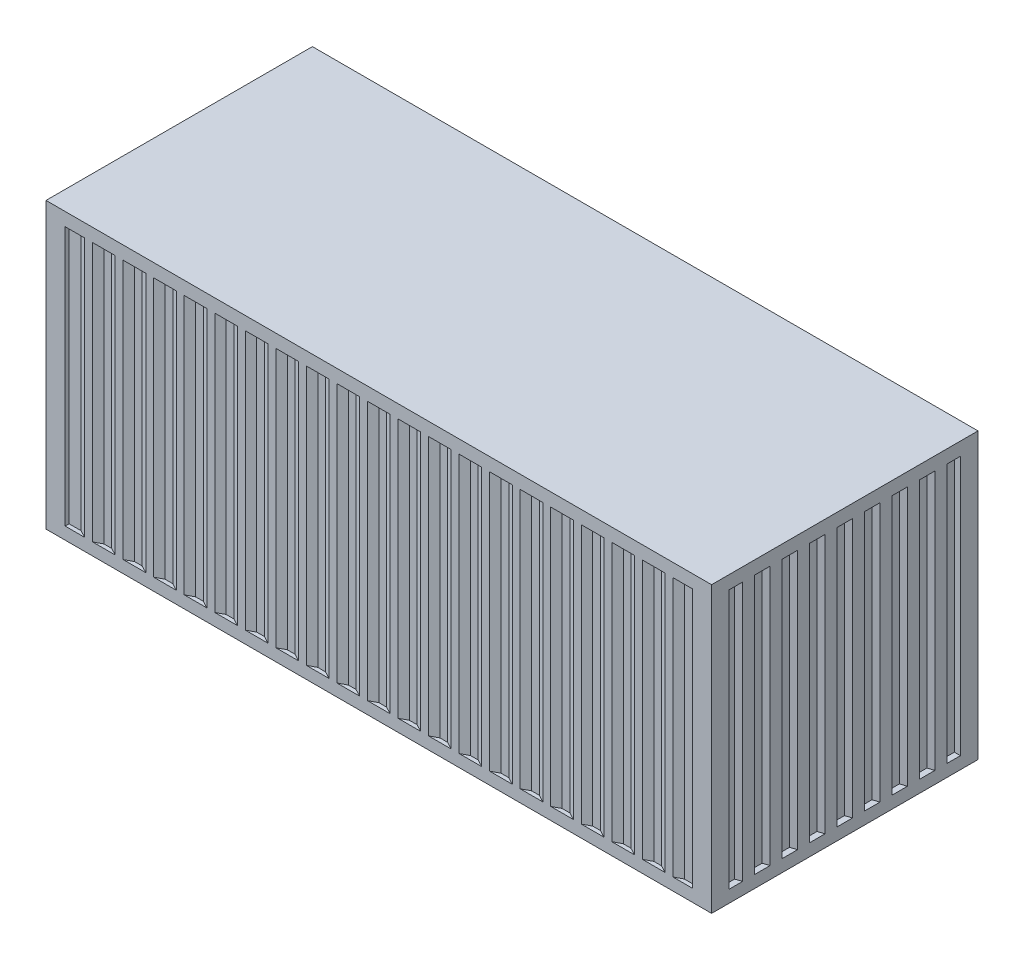
from build123d import *

# Parameters (mm, degrees)
SKETCH1_W           = 6058
SKETCH1_H           = 2424.7
BOSS_EXTRUDE1_DEPTH = 2591
CUT_EXTRUDE1_START  = -120
CUT_EXTRUDE1_DEPTH  = 2360


with BuildPart() as part:
    # Sketch1 → Boss-Extrude1 (new body)
    with BuildSketch(Plane(origin=(0, 0, 0), x_dir=(1, 0, 0), z_dir=(0, 1, 0))):
        with Locations((3029, 1212.35)):
            Rectangle(SKETCH1_W, SKETCH1_H)
    extrude(amount=BOSS_EXTRUDE1_DEPTH)

    # Sketch4 → Cut-Extrude1 (cut)
    with BuildSketch(Plane(origin=(0, 2591, 0), x_dir=(1, 0, 0), z_dir=(0, 1, 0)).offset(CUT_EXTRUDE1_START)):
        Polygon((6058, 2424.7), (5884, 2424.7), (5884, 2388.7), (5774, 2388.7), (5706, 2424.7), (5634, 2424.7), (5566, 2388.7), (5496, 2388.7), (5428, 2424.7), (5356, 2424.7), (5288, 2388.7), (5218, 2388.7), (5150, 2424.7), (5078, 2424.7), (5010, 2388.7), (4940, 2388.7), (4872, 2424.7), (4800, 2424.7), (4732, 2388.7), (4662, 2388.7), (4594, 2424.7), (4522, 2424.7), (4454, 2388.7), (4384, 2388.7), (4316, 2424.7), (4244, 2424.7), (4176, 2388.7), (4106, 2388.7), (4038, 2424.7), (3966, 2424.7), (3898, 2388.7), (3828, 2388.7), (3760, 2424.7), (3688, 2424.7), (3620, 2388.7), (3550, 2388.7), (3482, 2424.7), (3410, 2424.7), (3342, 2388.7), (3272, 2388.7), (3204, 2424.7), (3132, 2424.7), (3064, 2388.7), (2994, 2388.7), (2926, 2424.7), (2854, 2424.7), (2786, 2388.7), (2716, 2388.7), (2648, 2424.7), (2576, 2424.7), (2508, 2388.7), (2438, 2388.7), (2370, 2424.7), (2298, 2424.7), (2230, 2388.7), (2160, 2388.7), (2092, 2424.7), (2020, 2424.7), (1952, 2388.7), (1882, 2388.7), (1814, 2424.7), (1742, 2424.7), (1674, 2388.7), (1604, 2388.7), (1536, 2424.7), (1464, 2424.7), (1396, 2388.7), (1326, 2388.7), (1258, 2424.7), (1186, 2424.7), (1118, 2388.7), (1048, 2388.7), (980, 2424.7), (908, 2424.7), (840, 2388.7), (770, 2388.7), (702, 2424.7), (630, 2424.7), (562, 2388.7), (492, 2388.7), (424, 2424.7), (352, 2424.7), (284, 2388.7), (174, 2388.7), (174, 2424.7), (0, 2424.7), (-440.074917695, 2424.7), (-440.074917695, 3030.485706957), (7385.190687061, 3030.485706957), (7385.190687061, -895.463620642), (-1155.393639227, -895.463620642), (-1155.393639227, 0), (0, 0), (174, 0), (174, 36), (284, 36), (352, 0), (424, 0), (492, 36), (562, 36), (630, 0), (702, 0), (770, 36), (840, 36), (908, 0), (980, 0), (1048, 36), (1118, 36), (1186, 0), (1258, 0), (1326, 36), (1396, 36), (1464, 0), (1536, 0), (1604, 36), (1674, 36), (1742, 0), (1814, 0), (1882, 36), (1952, 36), (2020, 0), (2092, 0), (2160, 36), (2230, 36), (2298, 0), (2370, 0), (2438, 36), (2508, 36), (2576, 0), (2648, 0), (2716, 36), (2786, 36), (2854, 0), (2926, 0), (2994, 36), (3064, 36), (3132, 0), (3204, 0), (3272, 36), (3342, 36), (3410, 0), (3482, 0), (3550, 36), (3620, 36), (3688, 0), (3760, 0), (3828, 36), (3898, 36), (3966, 0), (4038, 0), (4106, 36), (4176, 36), (4244, 0), (4316, 0), (4384, 36), (4454, 36), (4522, 0), (4594, 0), (4662, 36), (4732, 36), (4800, 0), (4872, 0), (4940, 36), (5010, 36), (5078, 0), (5150, 0), (5218, 36), (5288, 36), (5356, 0), (5428, 0), (5496, 36), (5566, 36), (5634, 0), (5706, 0), (5774, 36), (5884, 36), (5884, 0), (6058, 0), (6058, 160), (6003, 160), (6003, 264.35), (6058, 282.35), (6058, 392.35), (6003, 410.35), (6003, 514.35), (6058, 532.35), (6058, 642.35), (6003, 660.35), (6003, 764.35), (6058, 782.35), (6058, 892.35), (6003, 910.35), (6003, 1014.35), (6058, 1032.35), (6058, 1142.35), (6003, 1160.35), (6003, 1264.35), (6058, 1282.35), (6058, 1392.35), (6003, 1410.35), (6003, 1514.35), (6058, 1532.35), (6058, 1642.35), (6003, 1660.35), (6003, 1764.35), (6058, 1782.35), (6058, 1892.35), (6003, 1910.35), (6003, 2014.35), (6058, 2032.35), (6058, 2142.35), (6003, 2160.35), (6003, 2264.7), (6058, 2264.7), align=None)
    extrude(amount=-CUT_EXTRUDE1_DEPTH, mode=Mode.SUBTRACT)


solid = part.part
